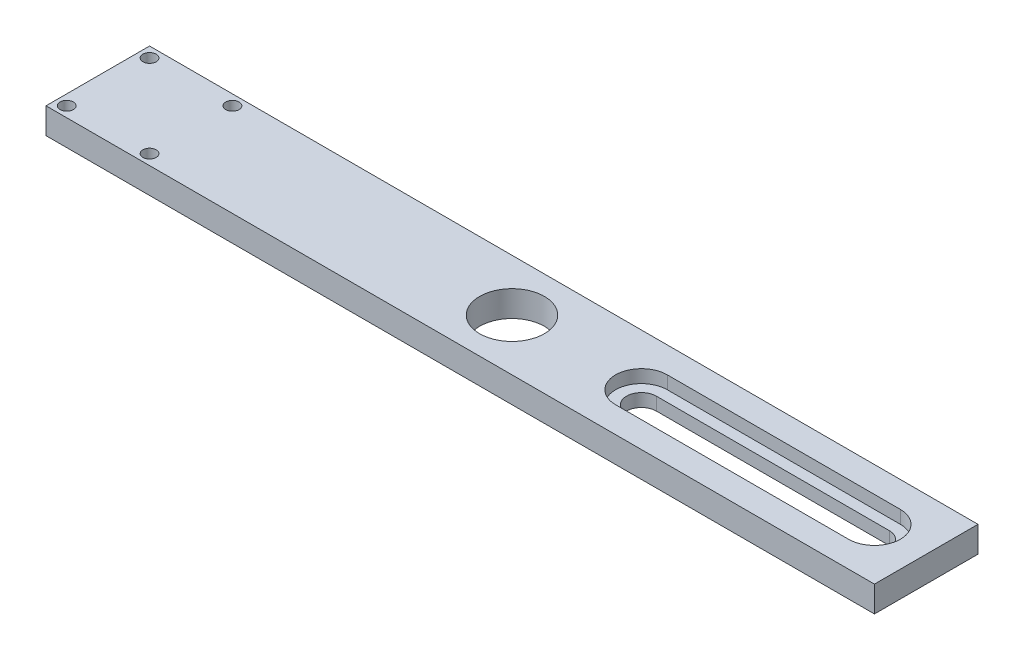
from build123d import *

# Parameters (mm, degrees)
SKETCH1_W                        = 203.2
SKETCH1_H                        = 25.4
BOSS_EXTRUDE1_DEPTH              = 6.35
F_5_8_0_625_DIAMETER_HOLE1_D     = 15.875
F_5_8_0_625_DIAMETER_HOLE1_DEPTH = 25.4
F_5_8_0_625_DIAMETER_HOLE1_TIP   = 4.769331164
CUT_EXTRUDE1_DEPTH               = 7.35
CUT_EXTRUDE2_DEPTH               = 3.175
F_4_CLEARANCE_HOLE1_D            = 3.2639


with BuildPart() as part:
    # Sketch1 → Boss-Extrude1 (new body)
    with BuildSketch(Plane(origin=(0, 0, 0), x_dir=(1, 0, 0), z_dir=(0, 1, 0))):
        with Locations((101.6, 12.7)):
            Rectangle(SKETCH1_W, SKETCH1_H)
    extrude(amount=BOSS_EXTRUDE1_DEPTH)

    # 5/8 (0.625) Diameter Hole1
    with Locations(Plane(origin=(0, 6.35, 0), x_dir=(1, 0, 0), z_dir=(0, 1, 0))):
        with Locations((101.6, 12.7)):
            Hole(F_5_8_0_625_DIAMETER_HOLE1_D / 2, depth=F_5_8_0_625_DIAMETER_HOLE1_DEPTH)
            with Locations((0, 0, -(F_5_8_0_625_DIAMETER_HOLE1_DEPTH + F_5_8_0_625_DIAMETER_HOLE1_TIP / 2))):  # 118° drill point
                Cone(0, F_5_8_0_625_DIAMETER_HOLE1_D / 2, F_5_8_0_625_DIAMETER_HOLE1_TIP, mode=Mode.SUBTRACT)

    # Sketch6 → Cut-Extrude1 (cut, through all)
    with BuildSketch(Plane(origin=(0, 6.35, 0), x_dir=(1, 0, 0), z_dir=(0, 1, 0))):
        with BuildLine():
            Line((133.35, 16.3576), (190.5, 16.3576))
            ThreePointArc((190.5, 16.3576), (194.1576, 12.7), (190.5, 9.0424))
            Line((190.5, 9.0424), (133.35, 9.0424))
            ThreePointArc((133.35, 9.0424), (129.6924, 12.7), (133.35, 16.3576))
        make_face()
    extrude(amount=-CUT_EXTRUDE1_DEPTH, mode=Mode.SUBTRACT)

    # Sketch7 → Cut-Extrude2 (cut)
    with BuildSketch(Plane(origin=(0, 6.35, 0), x_dir=(1, 0, 0), z_dir=(0, 1, 0))):
        with BuildLine():
            Line((190.5, 6.35), (133.35, 6.35))
            ThreePointArc((133.35, 6.35), (127, 12.7), (133.35, 19.05))
            Line((133.35, 19.05), (190.5, 19.05))
            ThreePointArc((190.5, 19.05), (196.85, 12.7), (190.5, 6.35))
        make_face()
    extrude(amount=-CUT_EXTRUDE2_DEPTH, mode=Mode.SUBTRACT)

    # #4 Clearance Hole1 (through all)
    with Locations(Plane(origin=(0, 6.35, 0), x_dir=(1, 0, 0), z_dir=(0, 1, 0))):
        with Locations((2.54, 22.86), (22.86, 22.86), (22.86, 2.54), (2.54, 2.54)):
            Hole(F_4_CLEARANCE_HOLE1_D / 2)


solid = part.part
